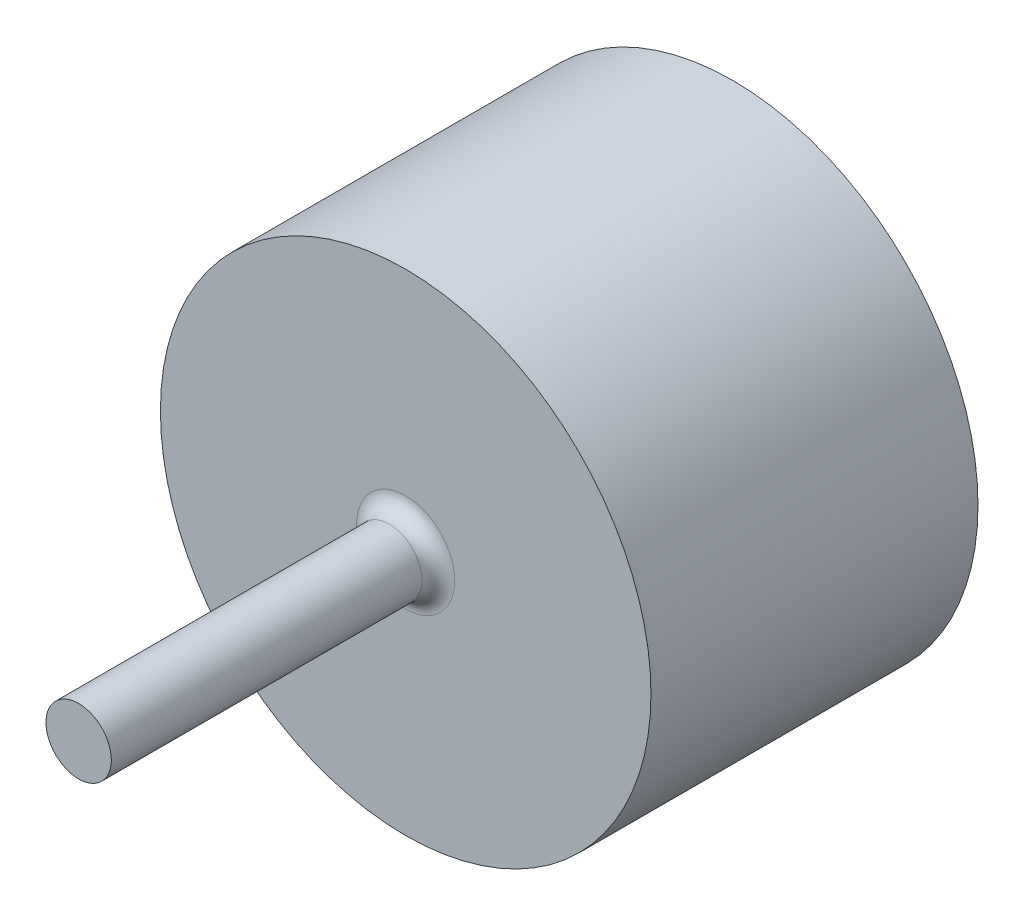
from build123d import *

# Parameters (mm, degrees)
SKETCH_1_R      = 75
EXTRUDE_1_DEPTH = 100
SKETCH_2_R      = 10
EXTRUDE_2_DEPTH = 100
FILLET_1_R      = 5


with BuildPart() as part:
    # 草图1 → 凸台-拉伸1 (new body)
    with BuildSketch(Plane.XY):
        Circle(SKETCH_1_R)
    extrude(amount=EXTRUDE_1_DEPTH)

    # 草图2 → 凸台-拉伸2 (add)
    with BuildSketch(Plane.XY.offset(100)):
        Circle(SKETCH_2_R)
    extrude(amount=EXTRUDE_2_DEPTH)

    # 圆角1
    fillet_1_edges = [part.edges().sort_by_distance(p)[0] for p in [
        (-10, 0, 100),
    ]]
    fillet(fillet_1_edges, radius=FILLET_1_R)


solid = part.part
